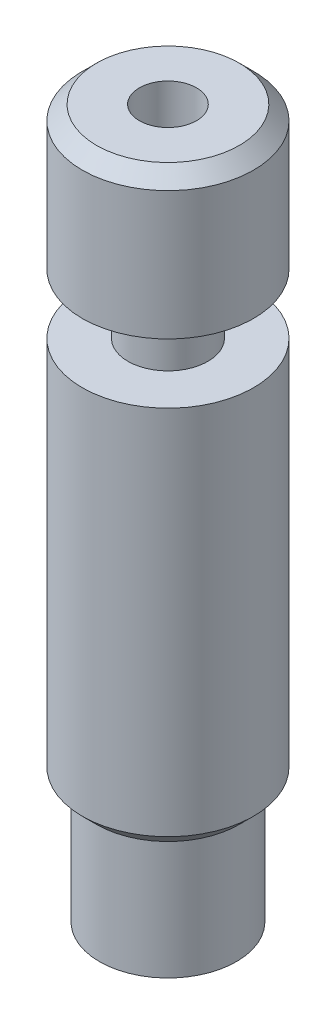
from build123d import *


with BuildPart() as part:
    # Sketch1 → Revolve1 (revolve)
    with BuildSketch(Plane.XY):
        Polygon((1, -12.15), (1, 12.55), (2.5, 12.55), (3, 12.05), (3, 7.55), (1.4, 7.55), (1.4, 5.45), (3, 5.45), (3, -7.55), (2.5, -8.05), (2.4, -8.05), (2.4, -12.261324865), (1.9, -12.55), (1.4, -12.55), align=None)
    revolve(axis=Axis((0, 12.55, 0), (0, -1, 0)))


solid = part.part
